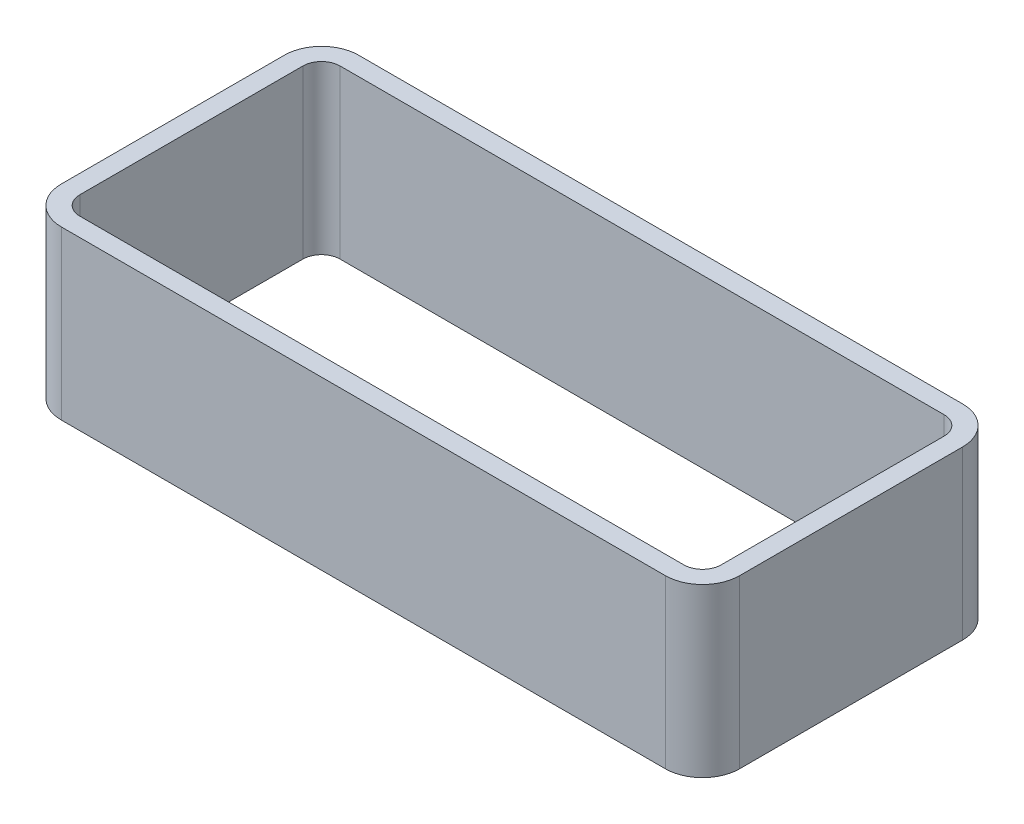
from build123d import *

# Parameters (mm, degrees)
BOSS_EXTRUDE2_DEPTH = 18


with BuildPart() as part:
    # Sketch1 → Boss-Extrude2 (new body)
    with BuildSketch(Plane(origin=(0, 0, 0), x_dir=(1, 0, 0), z_dir=(0, 1, 0))):
        with BuildLine():
            Line((-36.5, -12), (-36.5, 12))
            ThreePointArc((-36.5, 12), (-35.328427125, 14.828427125), (-32.5, 16))
            Line((-32.5, 16), (32.5, 16))
            ThreePointArc((32.5, 16), (35.328427125, 14.828427125), (36.5, 12))
            Line((36.5, 12), (36.5, -12))
            ThreePointArc((36.5, -12), (35.328427125, -14.828427125), (32.5, -16))
            Line((32.5, -16), (-32.5, -16))
            ThreePointArc((-32.5, -16), (-35.328427125, -14.828427125), (-36.5, -12))
        make_face()
        with BuildLine():
            Line((-32.5, -14), (32.5, -14))
            ThreePointArc((32.5, -14), (33.914213562, -13.414213562), (34.5, -12))
            Line((34.5, -12), (34.5, 12))
            ThreePointArc((34.5, 12), (33.914213562, 13.414213562), (32.5, 14))
            Line((32.5, 14), (-32.5, 14))
            ThreePointArc((-32.5, 14), (-33.914213562, 13.414213562), (-34.5, 12))
            Line((-34.5, 12), (-34.5, -12))
            ThreePointArc((-34.5, -12), (-33.914213562, -13.414213562), (-32.5, -14))
        make_face(mode=Mode.SUBTRACT)
    extrude(amount=BOSS_EXTRUDE2_DEPTH)


solid = part.part
